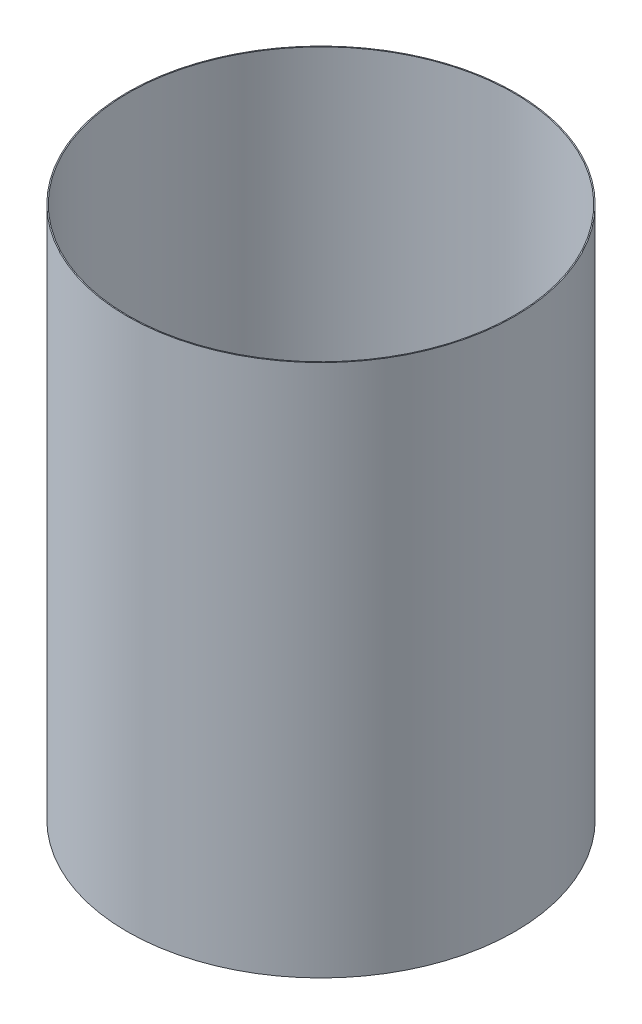
from build123d import *

# Parameters (mm, degrees)
SKETCH1_W = 0.254
SKETCH1_H = 133.35


with BuildPart() as part:
    # Sketch1 → Revolve-Thin1 (revolve)
    with BuildSketch(Plane.XY):
        with Locations((-48.387, -86.580914232)):
            Rectangle(SKETCH1_W, SKETCH1_H)
    revolve(axis=Axis((0, 55, 0), (0, -1, 0)))


solid = part.part
